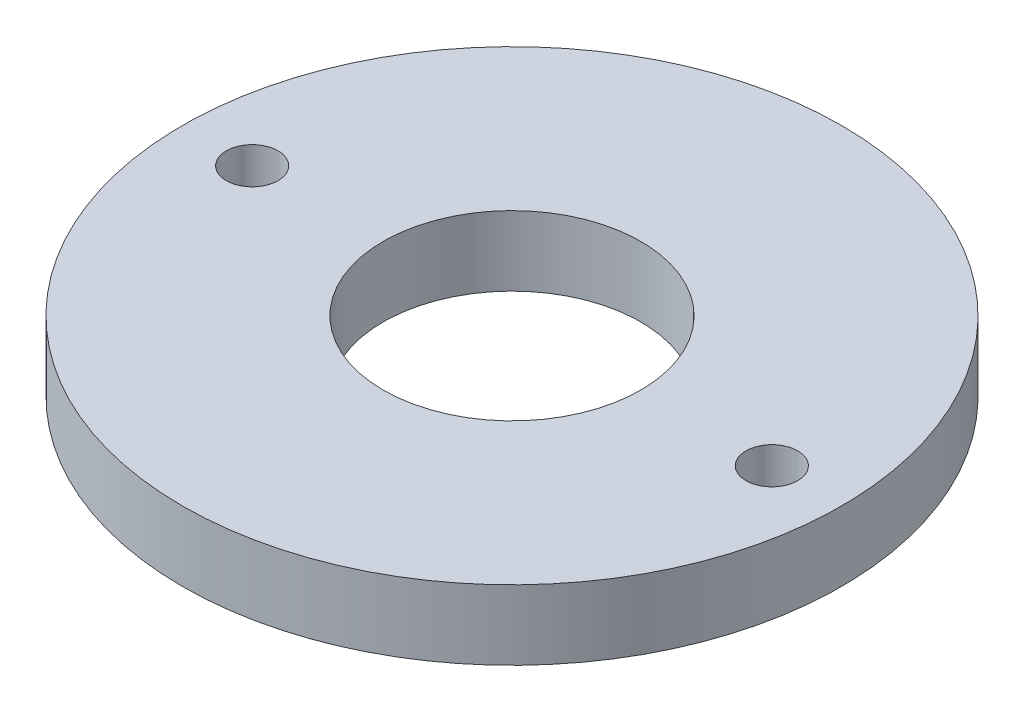
from build123d import *

# Parameters (mm, degrees)
SKETCH1_R           = 14.65
SKETCH1_R_2         = 5.725
SKETCH1_R_3         = 1.15
BOSS_EXTRUDE1_DEPTH = 3.1


with BuildPart() as part:
    # Sketch1 → Boss-Extrude1 (new body)
    with BuildSketch(Plane(origin=(0, 0, 0), x_dir=(1, 0, 0), z_dir=(0, 1, 0))):
        Circle(SKETCH1_R)
        Circle(SKETCH1_R_2, mode=Mode.SUBTRACT)
        with Locations((11.55, 0)):
            Circle(SKETCH1_R_3, mode=Mode.SUBTRACT)
        with Locations((-11.55, 0)):
            Circle(SKETCH1_R_3, mode=Mode.SUBTRACT)
    extrude(amount=BOSS_EXTRUDE1_DEPTH)


solid = part.part
